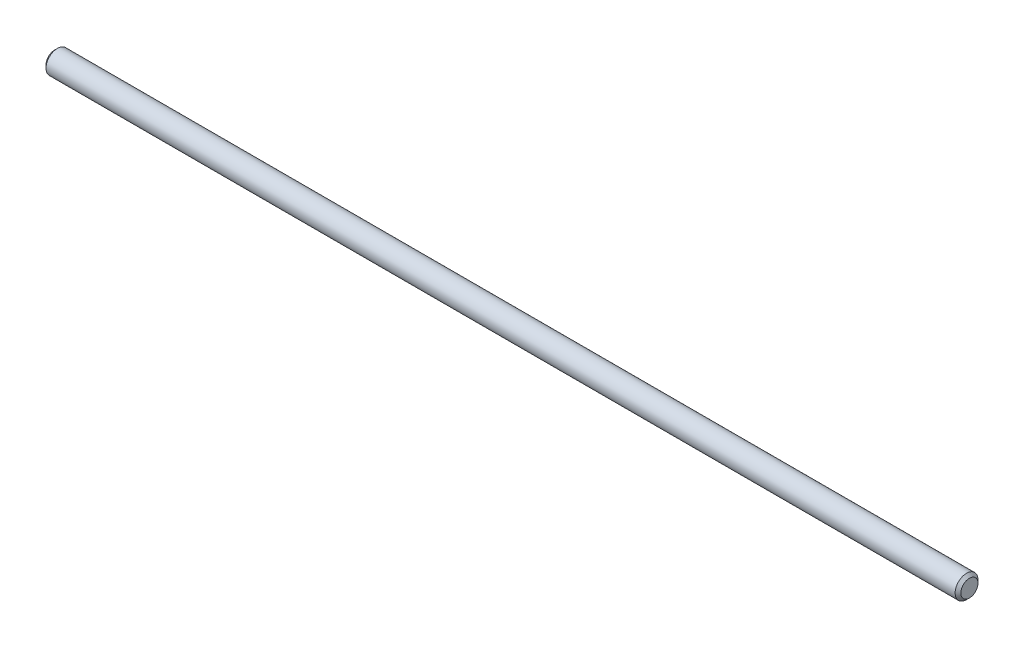
from build123d import *

# Parameters (mm, degrees)
SKETCH1_R           = 2
BOSS_EXTRUDE1_DEPTH = 80
CHAMFER1_SIZE       = 0.5


with BuildPart() as part:
    # Sketch1 → Boss-Extrude1 (new body, symmetric)
    with BuildSketch(Plane(origin=(0, 0, 0), x_dir=(0, 0, -1), z_dir=(1, 0, 0))):
        Circle(SKETCH1_R)
    extrude(amount=BOSS_EXTRUDE1_DEPTH, both=True)

    # Chamfer1
    chamfer1_edges = [part.edges().sort_by_distance(p)[0] for p in [
        (-80, 0, 2),
        (80, 0, 2),
    ]]
    chamfer(chamfer1_edges, length=CHAMFER1_SIZE)


solid = part.part
